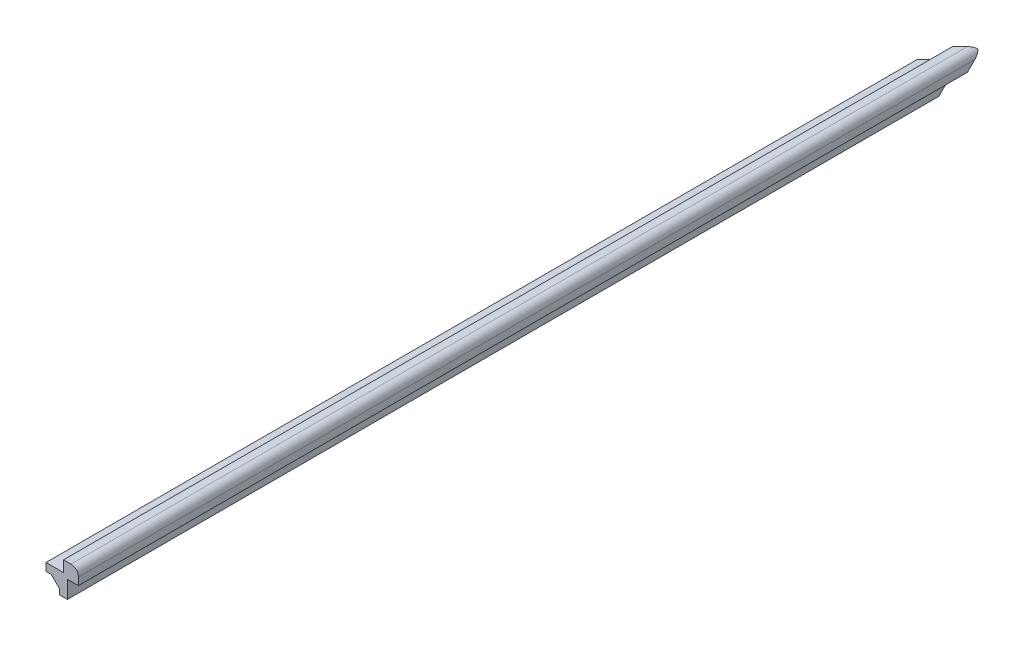
from build123d import *

# Parameters (mm, degrees)
SKETCH7_W               = 4.7625
SKETCH7_H               = 2.12122512
BOSS_EXTRUDE2_DEPTH     = 130.175
SKETCH8_W               = 2.12122512
SKETCH8_H               = 4.7625
BOSS_EXTRUDE3_DEPTH     = 130.175
BOSS_EXTRUDE4_DEPTH     = 130.175
CUT_EXTRUDE6_DEPTH      = 245.098438966
CUT_EXTRUDE6_DEPTH_BACK = 245.098438966


with BuildPart() as part:
    # Sketch7 → Boss-Extrude2 (new, symmetric)
    with BuildSketch(Plane.XY):
        with Locations((-4.92125, -2.560612608)):
            Rectangle(SKETCH7_W, SKETCH7_H)
    extrude(amount=BOSS_EXTRUDE2_DEPTH, both=True)

    # Sketch8 → Boss-Extrude3 (add, symmetric)
    with BuildSketch(Plane.XY):
        with Locations((-2.560612608, -4.92125)):
            Rectangle(SKETCH8_W, SKETCH8_H)
    extrude(amount=BOSS_EXTRUDE3_DEPTH, both=True)

    # Sketch11 → Boss-Extrude4 (add, symmetric)
    with BuildSketch(Plane.XY):
        with BuildLine():
            Line((-2.54, 1.500000048), (-2.54, -1.500000048))
            Line((-2.54, -1.500000048), (-7.3025, -1.500000048))
            Line((-7.3025, -1.500000048), (-7.3025, -3.621225168))
            Line((-7.3025, -3.621225168), (-5.866289198, -3.621225168))
            Line((-5.866289198, -3.621225168), (-3.621225168, -5.866289198))
            Line((-3.621225168, -5.866289198), (-3.621225168, -7.3025))
            Line((-3.621225168, -7.3025), (-1.500000048, -7.3025))
            Line((-1.500000048, -7.3025), (-1.500000048, -2.54))
            Line((-1.500000048, -2.54), (1.500000048, -2.54))
            Line((1.500000048, -2.54), (1.500000048, -0.519999976))
            ThreePointArc((1.500000048, -0.519999976), (0.908355739, 0.908355739), (-0.519999976, 1.500000048))
            Line((-0.519999976, 1.500000048), (-2.54, 1.500000048))
        make_face()
    extrude(amount=BOSS_EXTRUDE4_DEPTH, both=True)

    # Sketch18 → Cut-Extrude6 (cut, two sides: drawn at the far end of the back side and taken through both)
    with BuildSketch(Plane(origin=(0, 0, -113.704878), x_dir=(-0.707106781186546, 0, -0.707106781186549), z_dir=(-0.5773502691896265, -0.5773502691896261, 0.5773502691896247)).offset(-CUT_EXTRUDE6_DEPTH_BACK)):
        Polygon((0, 0), (0, -73.323484187), (63.5, 36.661742094), (-63.5, 36.661742094), align=None)
    extrude(amount=CUT_EXTRUDE6_DEPTH + CUT_EXTRUDE6_DEPTH_BACK, mode=Mode.SUBTRACT)


solid = part.part
